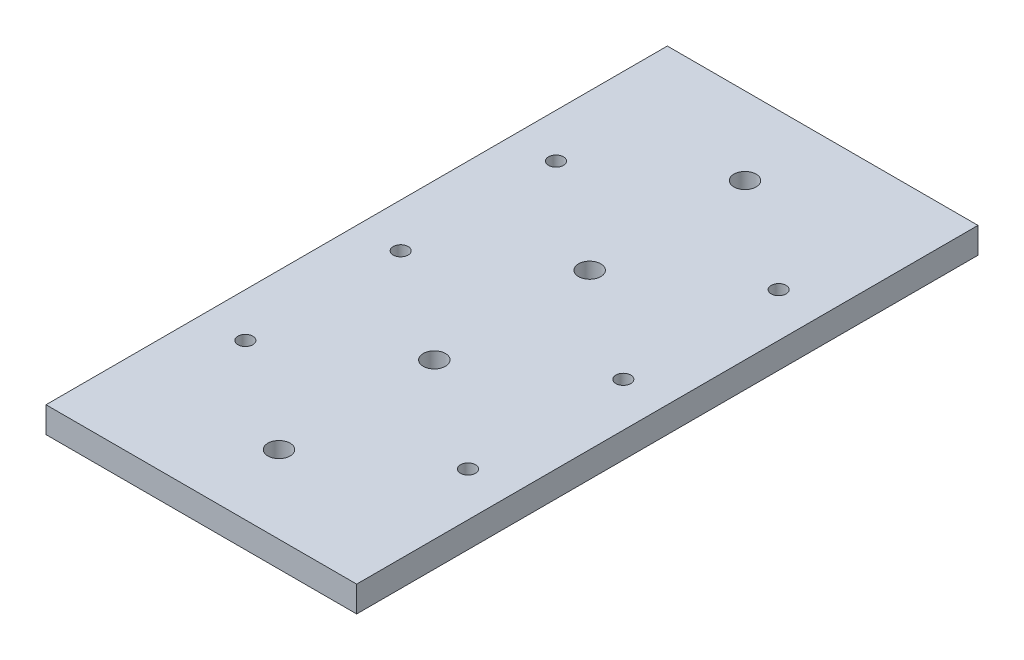
from build123d import *

# Parameters (mm, degrees)
SKETCH1_W           = 76.2
SKETCH1_H           = 152.4
SKETCH1_R           = 2.7305
SKETCH1_R_2         = 1.8288
BOSS_EXTRUDE1_DEPTH = 6.35


with BuildPart() as part:
    # Sketch1 → Boss-Extrude1 (new body)
    with BuildSketch(Plane(origin=(0, 0, 0), x_dir=(1, 0, 0), z_dir=(0, 1, 0))):
        Rectangle(SKETCH1_W, SKETCH1_H)
        with Locations((0, 57.15)):
            Circle(SKETCH1_R, mode=Mode.SUBTRACT)
        with Locations((0, 19.05)):
            Circle(SKETCH1_R, mode=Mode.SUBTRACT)
        with Locations((0, -19.05)):
            Circle(SKETCH1_R, mode=Mode.SUBTRACT)
        with Locations((0, -57.15)):
            Circle(SKETCH1_R, mode=Mode.SUBTRACT)
        with Locations((27.305, 38.1)):
            Circle(SKETCH1_R_2, mode=Mode.SUBTRACT)
        with Locations((27.305, 0)):
            Circle(SKETCH1_R_2, mode=Mode.SUBTRACT)
        with Locations((27.305, -38.1)):
            Circle(SKETCH1_R_2, mode=Mode.SUBTRACT)
        with Locations((-27.305, 0)):
            Circle(SKETCH1_R_2, mode=Mode.SUBTRACT)
        with Locations((-27.305, -38.1)):
            Circle(SKETCH1_R_2, mode=Mode.SUBTRACT)
        with Locations((-27.305, 38.1)):
            Circle(SKETCH1_R_2, mode=Mode.SUBTRACT)
    extrude(amount=-BOSS_EXTRUDE1_DEPTH)


solid = part.part
